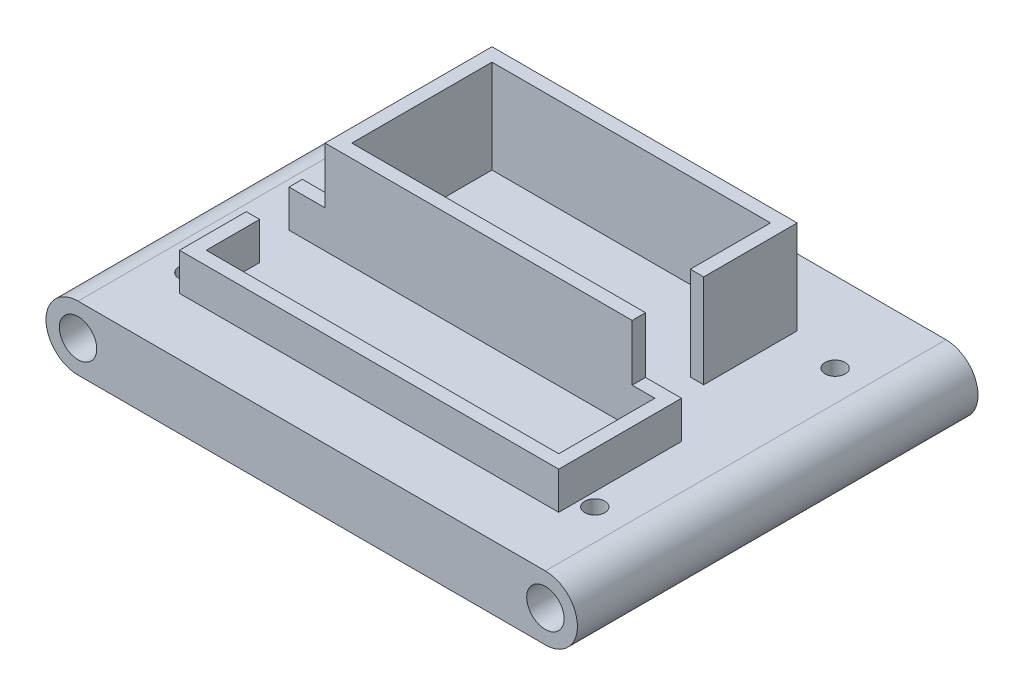
from build123d import *

# Parameters (mm, degrees)
SKETCH1_R           = 3.556
BOSS_EXTRUDE1_DEPTH = 76.2
SKETCH2_R           = 1.905
CUT_EXTRUDE1_DEPTH  = 6.604
SKETCH3_W           = 58.057716114
SKETCH3_H           = 2.54
SKETCH3_W_2         = 2.54
SKETCH3_H_2         = 26.67
SKETCH3_W_3         = 58.42
SKETCH3_H_3         = 15.24
BOSS_EXTRUDE2_DEPTH = 17.78
SKETCH4_W           = 6.858
SKETCH4_H           = 2.54
SKETCH4_W_2         = 2.54
SKETCH4_H_2         = 10.16
SKETCH4_H_3         = 18.288
BOSS_EXTRUDE3_DEPTH = 7.112
SKETCH5_R           = 1.905
CUT_EXTRUDE2_DEPTH  = 7.112


with BuildPart() as part:
    # Sketch1 → Boss-Extrude1 (new body)
    with BuildSketch(Plane.XY):
        with BuildLine():
            Line((-44.45, 6.096), (44.45, 6.096))
            ThreePointArc((44.45, 6.096), (50.546, 0), (44.45, -6.096))
            Line((44.45, -6.096), (-44.45, -6.096))
            ThreePointArc((-44.45, -6.096), (-50.546, 0), (-44.45, 6.096))
        make_face()
        with Locations((-44.45, 0)):
            Circle(SKETCH1_R, mode=Mode.SUBTRACT)
        with Locations((44.45, 0)):
            Circle(SKETCH1_R, mode=Mode.SUBTRACT)
    extrude(amount=BOSS_EXTRUDE1_DEPTH)

    # Sketch2 → Cut-Extrude1 (cut)
    with BuildSketch(Plane.XZ.offset(6.096)):
        with Locations((-9.144, 69.215)):
            Circle(SKETCH2_R)
        with Locations((27.051, 60.833)):
            Circle(SKETCH2_R)
        with Locations((-28.956, 69.215)):
            Circle(SKETCH2_R)
        with Locations((-28.956, 6.985)):
            Circle(SKETCH2_R)
        with Locations((-9.144, 6.985)):
            Circle(SKETCH2_R)
        with Locations((11.049, 60.833)):
            Circle(SKETCH2_R)
        with Locations((11.049, 15.367)):
            Circle(SKETCH2_R)
        with Locations((27.051, 15.367)):
            Circle(SKETCH2_R)
    extrude(amount=-CUT_EXTRUDE1_DEPTH, mode=Mode.SUBTRACT)

    # Sketch3 → Boss-Extrude2 (add)
    with BuildSketch(Plane(origin=(0, 6.096, 0), x_dir=(1, 0, 0), z_dir=(0, 1, 0))):
        with Locations((-0.181141943, -13.97)):
            Rectangle(SKETCH3_W, SKETCH3_H)
        with Locations((-27.94, -28.575)):
            Rectangle(SKETCH3_W_2, SKETCH3_H_2)
        with Locations((0, -43.18)):
            Rectangle(SKETCH3_W_3, SKETCH3_H)
        with Locations((27.577716114, -22.86)):
            Rectangle(SKETCH3_W_2, SKETCH3_H_3)
    extrude(amount=BOSS_EXTRUDE2_DEPTH)

    # Sketch4 → Boss-Extrude3 (add)
    with BuildSketch(Plane(origin=(0, 6.096, 0), x_dir=(1, 0, 0), z_dir=(0, 1, 0))):
        with Locations((-32.639, -43.18)):
            Rectangle(SKETCH4_W, SKETCH4_H)
        with Locations((-34.798, -57.658)):
            Rectangle(SKETCH4_W_2, SKETCH4_H_2)
        Polygon((36.068, -62.738), (33.528, -62.738), (-33.528, -62.738), (-36.068, -62.738), (-36.068, -65.278), (36.068, -65.278), align=None)
        with Locations((34.798, -53.594)):
            Rectangle(SKETCH4_W_2, SKETCH4_H_3)
        with Locations((32.639, -43.18)):
            Rectangle(SKETCH4_W, SKETCH4_H)
    extrude(amount=BOSS_EXTRUDE3_DEPTH)

    # Sketch5 → Cut-Extrude2 (cut)
    with BuildSketch(Plane(origin=(0, 6.096, 0), x_dir=(1, 0, 0), z_dir=(0, 1, 0))):
        with Locations((38.608, -60.96)):
            Circle(SKETCH5_R)
        with Locations((-38.608, -60.96)):
            Circle(SKETCH5_R)
        with Locations((-38.608, -15.24)):
            Circle(SKETCH5_R)
        with Locations((38.608, -15.24)):
            Circle(SKETCH5_R)
    extrude(amount=-CUT_EXTRUDE2_DEPTH, mode=Mode.SUBTRACT)


solid = part.part
